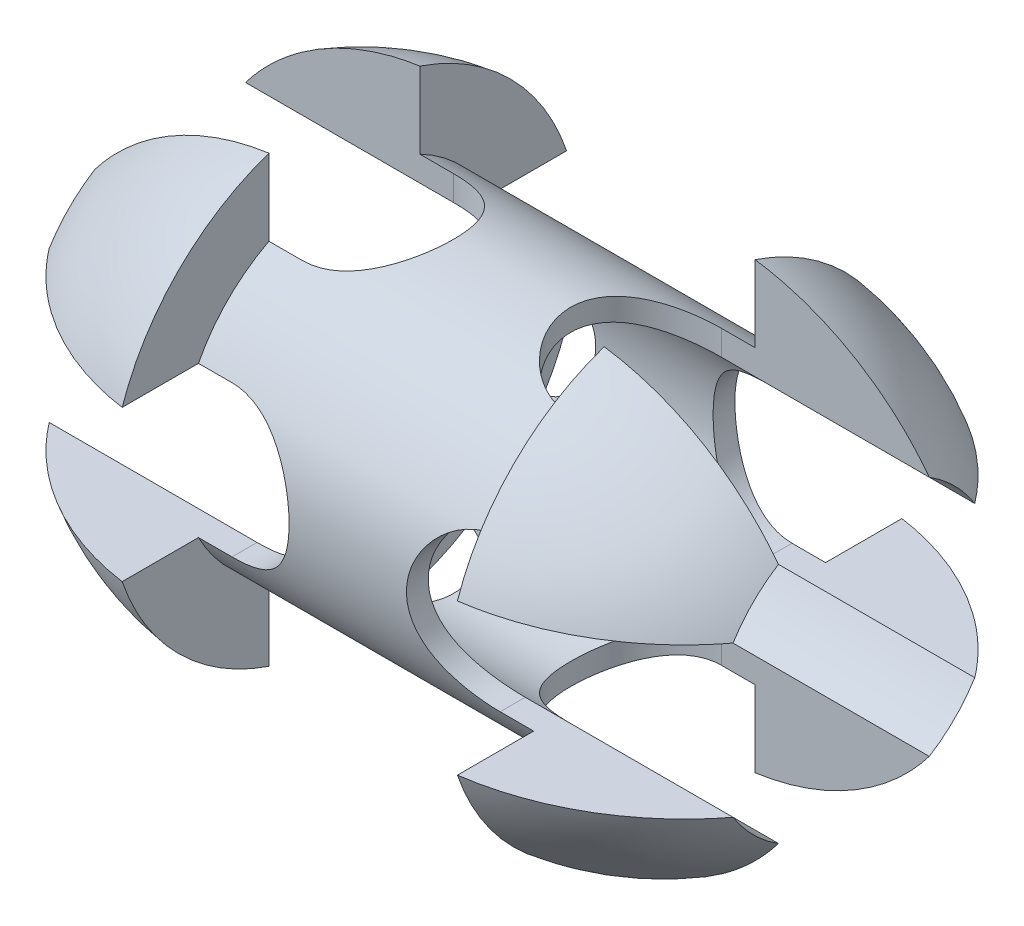
from build123d import *

# Parameters (mm, degrees)
CUT_EXTRUDE1_DEPTH = 15
CUT_EXTRUDE2_DEPTH = 15
SKETCH4_R          = 8.5
CUT_EXTRUDE3_DEPTH = 30


with BuildPart() as part:
    # Sketch1 → Revolve4 (revolve)
    with BuildSketch(Plane.XY):
        with BuildLine():
            Line((-10, 9.8), (-10, 14))
            ThreePointArc((-10, 14), (-19.548564966, 9.380656572), (-24.5, 0))
            Line((-24.5, 0), (-7, 0))
            Line((-7, 0), (7, 0))
            Line((7, 0), (24.5, 0))
            ThreePointArc((24.5, 0), (19.548564966, 9.380656572), (10, 14))
            Line((10, 14), (10, 9.8))
            Line((10, 9.8), (-10, 9.8))
        make_face()
    revolve(axis=Axis((-3.122498999, 0, 0), (1, 0, 0)))

    # Sketch2 → Cut-Extrude1 (cut, symmetric)
    with BuildSketch(Plane.XY):
        with BuildLine():
            Line((29, 4.5), (29, -4.5))
            Line((29, -4.5), (8, -4.5))
            ThreePointArc((8, -4.5), (3.5, 0), (8, 4.5))
            Line((8, 4.5), (29, 4.5))
        make_face()
        with BuildLine():
            Line((-29, 4.5), (-29, -4.5))
            Line((-29, -4.5), (-8, -4.5))
            ThreePointArc((-8, -4.5), (-3.5, 0), (-8, 4.5))
            Line((-8, 4.5), (-29, 4.5))
        make_face()
    extrude(amount=CUT_EXTRUDE1_DEPTH, both=True, mode=Mode.SUBTRACT)

    # Sketch3 → Cut-Extrude2 (cut, symmetric)
    with BuildSketch(Plane(origin=(0, 0, 0), x_dir=(1, 0, 0), z_dir=(0, 1, 0))):
        with BuildLine():
            Line((29, 4.5), (29, -4.5))
            Line((29, -4.5), (8, -4.5))
            ThreePointArc((8, -4.5), (3.5, 0), (8, 4.5))
            Line((8, 4.5), (29, 4.5))
        make_face()
        with BuildLine():
            Line((-29, -4.5), (-8, -4.5))
            ThreePointArc((-8, -4.5), (-3.5, 0), (-8, 4.5))
            Line((-8, 4.5), (-29, 4.5))
            Line((-29, 4.5), (-29, -4.5))
        make_face()
    extrude(amount=CUT_EXTRUDE2_DEPTH, both=True, mode=Mode.SUBTRACT)

    # Sketch4 → Cut-Extrude3 (cut, symmetric)
    with BuildSketch(Plane(origin=(0, 0, 0), x_dir=(0, 0, -1), z_dir=(1, 0, 0))):
        Circle(SKETCH4_R)
    extrude(amount=CUT_EXTRUDE3_DEPTH, both=True, mode=Mode.SUBTRACT)


solid = part.part
